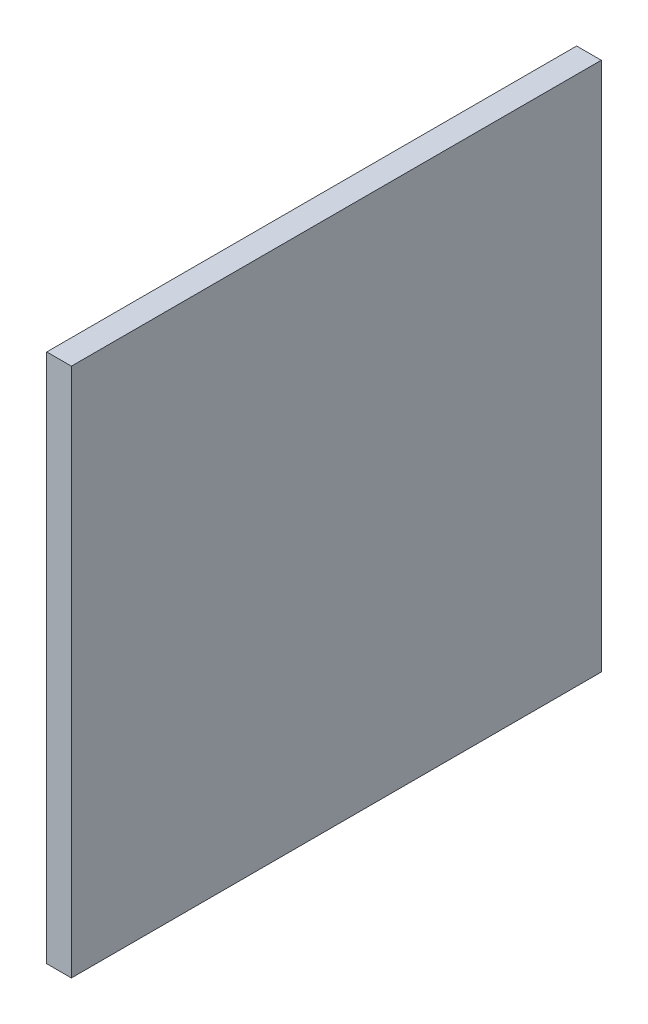
from build123d import *

# Parameters (mm, degrees)
SKETCH2_W              = 43
SKETCH2_H              = 43
BOSS_EXTRUDE1_DEPTH    = 2
SKETCH3_R              = 1.5
BOSS_EXTRUDE5_DEPTH    = 4
SKETCH5_R              = 1.5
BOSS_EXTRUDE6_DEPTH    = 4
BOSS_EXTRUDE6_2_DEPTH  = 4
BOSS_EXTRUDE6_3_DEPTH  = 4
BOSS_EXTRUDE6_4_DEPTH  = 4
BOSS_EXTRUDE6_5_DEPTH  = 4
BOSS_EXTRUDE6_6_DEPTH  = 4
BOSS_EXTRUDE6_7_DEPTH  = 4
BOSS_EXTRUDE6_8_DEPTH  = 4
SKETCH5_R_2            = 1.51
BOSS_EXTRUDE6_9_DEPTH  = 4
BOSS_EXTRUDE6_10_DEPTH = 4
BOSS_EXTRUDE6_11_DEPTH = 4
BOSS_EXTRUDE6_12_DEPTH = 4
BOSS_EXTRUDE6_13_DEPTH = 4
BOSS_EXTRUDE6_14_DEPTH = 4
BOSS_EXTRUDE6_15_DEPTH = 4
BOSS_EXTRUDE6_16_DEPTH = 4
BOSS_EXTRUDE6_17_DEPTH = 4
BOSS_EXTRUDE6_18_DEPTH = 4
BOSS_EXTRUDE6_19_DEPTH = 4
BOSS_EXTRUDE6_20_DEPTH = 4
BOSS_EXTRUDE6_21_DEPTH = 4
BOSS_EXTRUDE6_22_DEPTH = 4
BOSS_EXTRUDE6_23_DEPTH = 4
BOSS_EXTRUDE6_24_DEPTH = 4
BOSS_EXTRUDE6_25_DEPTH = 4
BOSS_EXTRUDE6_26_DEPTH = 4
BOSS_EXTRUDE6_27_DEPTH = 4
BOSS_EXTRUDE6_28_DEPTH = 4
BOSS_EXTRUDE6_29_DEPTH = 4
BOSS_EXTRUDE6_30_DEPTH = 4
BOSS_EXTRUDE6_31_DEPTH = 4
BOSS_EXTRUDE6_32_DEPTH = 4
BOSS_EXTRUDE6_33_DEPTH = 4
BOSS_EXTRUDE6_34_DEPTH = 4
BOSS_EXTRUDE6_35_DEPTH = 4
BOSS_EXTRUDE6_36_DEPTH = 4
BOSS_EXTRUDE6_37_DEPTH = 4
BOSS_EXTRUDE6_38_DEPTH = 4
BOSS_EXTRUDE6_39_DEPTH = 4
BOSS_EXTRUDE6_40_DEPTH = 4
BOSS_EXTRUDE6_41_DEPTH = 4
BOSS_EXTRUDE6_42_DEPTH = 4
BOSS_EXTRUDE6_43_DEPTH = 4
BOSS_EXTRUDE6_44_DEPTH = 4
BOSS_EXTRUDE6_45_DEPTH = 4
BOSS_EXTRUDE6_46_DEPTH = 4
BOSS_EXTRUDE6_47_DEPTH = 4
BOSS_EXTRUDE6_48_DEPTH = 4
BOSS_EXTRUDE6_49_DEPTH = 4
BOSS_EXTRUDE6_50_DEPTH = 4
BOSS_EXTRUDE6_51_DEPTH = 4
BOSS_EXTRUDE6_52_DEPTH = 4
BOSS_EXTRUDE6_53_DEPTH = 4
BOSS_EXTRUDE6_54_DEPTH = 4
BOSS_EXTRUDE6_55_DEPTH = 4
BOSS_EXTRUDE6_56_DEPTH = 4
FILLET3_R              = 1
FILLET4_R              = 1
FILLET5_R              = 1
FILLET6_R              = 1
FILLET7_R              = 1
FILLET8_R              = 1
FILLET9_R              = 1
FILLET10_R             = 1
FILLET11_R             = 1
FILLET12_R             = 1
FILLET13_R             = 1
FILLET14_R             = 1
FILLET15_R             = 1
FILLET16_R             = 1
FILLET17_R             = 1
FILLET18_R             = 1
FILLET19_R             = 1
FILLET20_R             = 1
FILLET21_R             = 1
FILLET22_R             = 1
FILLET23_R             = 1
FILLET24_R             = 1
FILLET25_R             = 1
FILLET26_R             = 1
FILLET27_R             = 1
FILLET28_R             = 1
FILLET29_R             = 1
FILLET30_R             = 1
FILLET31_R             = 1
FILLET32_R             = 1
FILLET33_R             = 1
FILLET34_R             = 1
FILLET35_R             = 1
FILLET36_R             = 1
FILLET37_R             = 1
FILLET38_R             = 1
FILLET39_R             = 1
FILLET40_R             = 1
FILLET41_R             = 1
FILLET42_R             = 1
FILLET43_R             = 1
FILLET44_R             = 1
FILLET45_R             = 1
FILLET46_R             = 1
FILLET47_R             = 1
FILLET48_R             = 1
FILLET49_R             = 1
FILLET50_R             = 1
FILLET51_R             = 1
FILLET52_R             = 1
FILLET53_R             = 1
FILLET54_R             = 1
FILLET55_R             = 1
FILLET56_R             = 1
FILLET57_R             = 1
FILLET58_R             = 1
FILLET59_R             = 1
FILLET60_R             = 1


with BuildPart() as part:
    # Sketch2 → Boss-Extrude1 (new body)
    with BuildSketch(Plane(origin=(0, 0, 0), x_dir=(0, 0, -1), z_dir=(1, 0, 0))):
        with Locations((21.5, 21.5)):
            Rectangle(SKETCH2_W, SKETCH2_H)
    extrude(amount=BOSS_EXTRUDE1_DEPTH)

    # Sketch3 → Boss-Extrude5 (add)
    with BuildSketch(Plane(origin=(0, 0, 0), x_dir=(0, 0, -1), z_dir=(1, 0, 0))):
        with Locations((6.1, 36.65749204)):
            Circle(SKETCH3_R)
        with Locations((10.4, 36.65749204)):
            Circle(SKETCH3_R)
        with Locations((14.7, 36.65749204)):
            Circle(SKETCH3_R)
        with Locations((19, 36.65749204)):
            Circle(SKETCH3_R)
        with Locations((23.3, 36.65749204)):
            Circle(SKETCH3_R)
        with Locations((27.6, 36.65749204)):
            Circle(SKETCH3_R)
        with Locations((31.93, 36.65749204)):
            Circle(SKETCH3_R)
        with Locations((36.23, 36.65749204)):
            Circle(SKETCH3_R)
    extrude(amount=-BOSS_EXTRUDE5_DEPTH)

    # Fillet3
    fillet3_edges = [part.edges().sort_by_distance(p)[0] for p in [
        (-4, 36.65749204, -34.73),
    ]]
    fillet(fillet3_edges, radius=FILLET3_R)

    # Fillet4
    fillet4_edges = [part.edges().sort_by_distance(p)[0] for p in [
        (-4, 36.65749204, -4.6),
        (-4, 36.65749204, -13.2),
        (-4, 36.65749204, -8.9),
        (-4, 36.65749204, -17.5),
        (-4, 36.65749204, -26.1),
        (-4, 36.65749204, -30.43),
        (-4, 36.65749204, -21.8),
    ]]
    fillet(fillet4_edges, radius=FILLET4_R)


with BuildPart() as body_2:
    # Sketch5 → Boss-Extrude6 (new body)
    with BuildSketch(Plane(origin=(0, 0, 0), x_dir=(0, 0, -1), z_dir=(1, 0, 0))):
        with Locations((36.23, 32.354858463)):
            Circle(SKETCH5_R)
    extrude(amount=-BOSS_EXTRUDE6_DEPTH)

    # Fillet5
    fillet5_edges = [body_2.edges().sort_by_distance(p)[0] for p in [
        (-4, 32.354858463, -34.73),
    ]]
    fillet(fillet5_edges, radius=FILLET5_R)


with BuildPart() as body_3:
    # Sketch5 → Boss-Extrude6 2 (new body)
    with BuildSketch(Plane(origin=(0, 0, 0), x_dir=(0, 0, -1), z_dir=(1, 0, 0))):
        with Locations((31.933627596, 32.354858463)):
            Circle(SKETCH5_R)
    extrude(amount=-BOSS_EXTRUDE6_2_DEPTH)

    # Fillet6
    fillet6_edges = [body_3.edges().sort_by_distance(p)[0] for p in [
        (-4, 32.354858463, -30.433627596),
    ]]
    fillet(fillet6_edges, radius=FILLET6_R)


with BuildPart() as body_4:
    # Sketch5 → Boss-Extrude6 3 (new body)
    with BuildSketch(Plane(origin=(0, 0, 0), x_dir=(0, 0, -1), z_dir=(1, 0, 0))):
        with Locations((27.633627596, 32.354858463)):
            Circle(SKETCH5_R)
    extrude(amount=-BOSS_EXTRUDE6_3_DEPTH)

    # Fillet7
    fillet7_edges = [body_4.edges().sort_by_distance(p)[0] for p in [
        (-4, 32.354858463, -26.133627596),
    ]]
    fillet(fillet7_edges, radius=FILLET7_R)


with BuildPart() as body_5:
    # Sketch5 → Boss-Extrude6 4 (new body)
    with BuildSketch(Plane(origin=(0, 0, 0), x_dir=(0, 0, -1), z_dir=(1, 0, 0))):
        with Locations((23.333627596, 32.354858463)):
            Circle(SKETCH5_R)
    extrude(amount=-BOSS_EXTRUDE6_4_DEPTH)

    # Fillet8
    fillet8_edges = [body_5.edges().sort_by_distance(p)[0] for p in [
        (-4, 32.354858463, -21.833627596),
    ]]
    fillet(fillet8_edges, radius=FILLET8_R)


with BuildPart() as body_6:
    # Sketch5 → Boss-Extrude6 5 (new body)
    with BuildSketch(Plane(origin=(0, 0, 0), x_dir=(0, 0, -1), z_dir=(1, 0, 0))):
        with Locations((19.033627596, 32.354858463)):
            Circle(SKETCH5_R)
    extrude(amount=-BOSS_EXTRUDE6_5_DEPTH)

    # Fillet9
    fillet9_edges = [body_6.edges().sort_by_distance(p)[0] for p in [
        (-4, 32.354858463, -17.533627596),
    ]]
    fillet(fillet9_edges, radius=FILLET9_R)


with BuildPart() as body_7:
    # Sketch5 → Boss-Extrude6 6 (new body)
    with BuildSketch(Plane(origin=(0, 0, 0), x_dir=(0, 0, -1), z_dir=(1, 0, 0))):
        with Locations((14.733627596, 32.354858463)):
            Circle(SKETCH5_R)
    extrude(amount=-BOSS_EXTRUDE6_6_DEPTH)

    # Fillet10
    fillet10_edges = [body_7.edges().sort_by_distance(p)[0] for p in [
        (-4, 32.354858463, -13.233627596),
    ]]
    fillet(fillet10_edges, radius=FILLET10_R)


with BuildPart() as body_8:
    # Sketch5 → Boss-Extrude6 7 (new body)
    with BuildSketch(Plane(origin=(0, 0, 0), x_dir=(0, 0, -1), z_dir=(1, 0, 0))):
        with Locations((10.433627596, 32.354858463)):
            Circle(SKETCH5_R)
    extrude(amount=-BOSS_EXTRUDE6_7_DEPTH)

    # Fillet11
    fillet11_edges = [body_8.edges().sort_by_distance(p)[0] for p in [
        (-4, 32.354858463, -8.933627596),
    ]]
    fillet(fillet11_edges, radius=FILLET11_R)


with BuildPart() as body_9:
    # Sketch5 → Boss-Extrude6 8 (new body)
    with BuildSketch(Plane(origin=(0, 0, 0), x_dir=(0, 0, -1), z_dir=(1, 0, 0))):
        with Locations((6.133627596, 32.354858463)):
            Circle(SKETCH5_R)
    extrude(amount=-BOSS_EXTRUDE6_8_DEPTH)

    # Fillet12
    fillet12_edges = [body_9.edges().sort_by_distance(p)[0] for p in [
        (-4, 32.354858463, -4.633627596),
    ]]
    fillet(fillet12_edges, radius=FILLET12_R)


with BuildPart() as body_10:
    # Sketch5 → Boss-Extrude6 9 (new body)
    with BuildSketch(Plane(origin=(0, 0, 0), x_dir=(0, 0, -1), z_dir=(1, 0, 0))):
        with Locations((6.133627596, 28.054858463)):
            Circle(SKETCH5_R_2)
    extrude(amount=-BOSS_EXTRUDE6_9_DEPTH)

    # Fillet19
    fillet19_edges = [body_10.edges().sort_by_distance(p)[0] for p in [
        (-4, 28.054858463, -4.623627596),
    ]]
    fillet(fillet19_edges, radius=FILLET19_R)


with BuildPart() as body_11:
    # Sketch5 → Boss-Extrude6 10 (new body)
    with BuildSketch(Plane(origin=(0, 0, 0), x_dir=(0, 0, -1), z_dir=(1, 0, 0))):
        with Locations((10.433627596, 28.054858463)):
            Circle(SKETCH5_R)
    extrude(amount=-BOSS_EXTRUDE6_10_DEPTH)

    # Fillet20
    fillet20_edges = [body_11.edges().sort_by_distance(p)[0] for p in [
        (-4, 28.054858463, -8.933627596),
    ]]
    fillet(fillet20_edges, radius=FILLET20_R)


with BuildPart() as body_12:
    # Sketch5 → Boss-Extrude6 11 (new body)
    with BuildSketch(Plane(origin=(0, 0, 0), x_dir=(0, 0, -1), z_dir=(1, 0, 0))):
        with Locations((14.733627596, 28.054858463)):
            Circle(SKETCH5_R)
    extrude(amount=-BOSS_EXTRUDE6_11_DEPTH)

    # Fillet18
    fillet18_edges = [body_12.edges().sort_by_distance(p)[0] for p in [
        (-4, 28.054858463, -13.233627596),
    ]]
    fillet(fillet18_edges, radius=FILLET18_R)


with BuildPart() as body_13:
    # Sketch5 → Boss-Extrude6 12 (new body)
    with BuildSketch(Plane(origin=(0, 0, 0), x_dir=(0, 0, -1), z_dir=(1, 0, 0))):
        with Locations((19.033627596, 28.054858463)):
            Circle(SKETCH5_R)
    extrude(amount=-BOSS_EXTRUDE6_12_DEPTH)

    # Fillet17
    fillet17_edges = [body_13.edges().sort_by_distance(p)[0] for p in [
        (-4, 28.054858463, -17.533627596),
    ]]
    fillet(fillet17_edges, radius=FILLET17_R)


with BuildPart() as body_14:
    # Sketch5 → Boss-Extrude6 13 (new body)
    with BuildSketch(Plane(origin=(0, 0, 0), x_dir=(0, 0, -1), z_dir=(1, 0, 0))):
        with Locations((23.333627596, 28.054858463)):
            Circle(SKETCH5_R)
    extrude(amount=-BOSS_EXTRUDE6_13_DEPTH)

    # Fillet16
    fillet16_edges = [body_14.edges().sort_by_distance(p)[0] for p in [
        (-4, 28.054858463, -21.833627596),
    ]]
    fillet(fillet16_edges, radius=FILLET16_R)


with BuildPart() as body_15:
    # Sketch5 → Boss-Extrude6 14 (new body)
    with BuildSketch(Plane(origin=(0, 0, 0), x_dir=(0, 0, -1), z_dir=(1, 0, 0))):
        with Locations((27.633627596, 28.054858463)):
            Circle(SKETCH5_R)
    extrude(amount=-BOSS_EXTRUDE6_14_DEPTH)

    # Fillet15
    fillet15_edges = [body_15.edges().sort_by_distance(p)[0] for p in [
        (-4, 28.054858463, -26.133627596),
    ]]
    fillet(fillet15_edges, radius=FILLET15_R)


with BuildPart() as body_16:
    # Sketch5 → Boss-Extrude6 15 (new body)
    with BuildSketch(Plane(origin=(0, 0, 0), x_dir=(0, 0, -1), z_dir=(1, 0, 0))):
        with Locations((31.933627596, 28.054858463)):
            Circle(SKETCH5_R)
    extrude(amount=-BOSS_EXTRUDE6_15_DEPTH)

    # Fillet14
    fillet14_edges = [body_16.edges().sort_by_distance(p)[0] for p in [
        (-4, 28.054858463, -30.433627596),
    ]]
    fillet(fillet14_edges, radius=FILLET14_R)


with BuildPart() as body_17:
    # Sketch5 → Boss-Extrude6 16 (new body)
    with BuildSketch(Plane(origin=(0, 0, 0), x_dir=(0, 0, -1), z_dir=(1, 0, 0))):
        with Locations((36.23, 28.054858463)):
            Circle(SKETCH5_R)
    extrude(amount=-BOSS_EXTRUDE6_16_DEPTH)

    # Fillet13
    fillet13_edges = [body_17.edges().sort_by_distance(p)[0] for p in [
        (-4, 28.054858463, -34.73),
    ]]
    fillet(fillet13_edges, radius=FILLET13_R)


with BuildPart() as body_18:
    # Sketch5 → Boss-Extrude6 17 (new body)
    with BuildSketch(Plane(origin=(0, 0, 0), x_dir=(0, 0, -1), z_dir=(1, 0, 0))):
        with Locations((36.23, 23.754858463)):
            Circle(SKETCH5_R)
    extrude(amount=-BOSS_EXTRUDE6_17_DEPTH)

    # Fillet28
    fillet28_edges = [body_18.edges().sort_by_distance(p)[0] for p in [
        (-4, 23.754858463, -34.73),
    ]]
    fillet(fillet28_edges, radius=FILLET28_R)


with BuildPart() as body_19:
    # Sketch5 → Boss-Extrude6 18 (new body)
    with BuildSketch(Plane(origin=(0, 0, 0), x_dir=(0, 0, -1), z_dir=(1, 0, 0))):
        with Locations((31.933627596, 23.754858463)):
            Circle(SKETCH5_R)
    extrude(amount=-BOSS_EXTRUDE6_18_DEPTH)

    # Fillet27
    fillet27_edges = [body_19.edges().sort_by_distance(p)[0] for p in [
        (-4, 23.754858463, -30.433627596),
    ]]
    fillet(fillet27_edges, radius=FILLET27_R)


with BuildPart() as body_20:
    # Sketch5 → Boss-Extrude6 19 (new body)
    with BuildSketch(Plane(origin=(0, 0, 0), x_dir=(0, 0, -1), z_dir=(1, 0, 0))):
        with Locations((27.633627596, 23.754858463)):
            Circle(SKETCH5_R)
    extrude(amount=-BOSS_EXTRUDE6_19_DEPTH)

    # Fillet26
    fillet26_edges = [body_20.edges().sort_by_distance(p)[0] for p in [
        (-4, 23.754858463, -26.133627596),
    ]]
    fillet(fillet26_edges, radius=FILLET26_R)


with BuildPart() as body_21:
    # Sketch5 → Boss-Extrude6 20 (new body)
    with BuildSketch(Plane(origin=(0, 0, 0), x_dir=(0, 0, -1), z_dir=(1, 0, 0))):
        with Locations((23.333627596, 23.754858463)):
            Circle(SKETCH5_R)
    extrude(amount=-BOSS_EXTRUDE6_20_DEPTH)

    # Fillet25
    fillet25_edges = [body_21.edges().sort_by_distance(p)[0] for p in [
        (-4, 23.754858463, -21.833627596),
    ]]
    fillet(fillet25_edges, radius=FILLET25_R)


with BuildPart() as body_22:
    # Sketch5 → Boss-Extrude6 21 (new body)
    with BuildSketch(Plane(origin=(0, 0, 0), x_dir=(0, 0, -1), z_dir=(1, 0, 0))):
        with Locations((19.033627596, 23.754858463)):
            Circle(SKETCH5_R)
    extrude(amount=-BOSS_EXTRUDE6_21_DEPTH)

    # Fillet24
    fillet24_edges = [body_22.edges().sort_by_distance(p)[0] for p in [
        (-4, 23.754858463, -17.533627596),
    ]]
    fillet(fillet24_edges, radius=FILLET24_R)


with BuildPart() as body_23:
    # Sketch5 → Boss-Extrude6 22 (new body)
    with BuildSketch(Plane(origin=(0, 0, 0), x_dir=(0, 0, -1), z_dir=(1, 0, 0))):
        with Locations((14.733627596, 23.754858463)):
            Circle(SKETCH5_R)
    extrude(amount=-BOSS_EXTRUDE6_22_DEPTH)

    # Fillet23
    fillet23_edges = [body_23.edges().sort_by_distance(p)[0] for p in [
        (-4, 23.754858463, -13.233627596),
    ]]
    fillet(fillet23_edges, radius=FILLET23_R)


with BuildPart() as body_24:
    # Sketch5 → Boss-Extrude6 23 (new body)
    with BuildSketch(Plane(origin=(0, 0, 0), x_dir=(0, 0, -1), z_dir=(1, 0, 0))):
        with Locations((10.433627596, 23.754858463)):
            Circle(SKETCH5_R)
    extrude(amount=-BOSS_EXTRUDE6_23_DEPTH)

    # Fillet21
    fillet21_edges = [body_24.edges().sort_by_distance(p)[0] for p in [
        (-4, 23.754858463, -8.933627596),
    ]]
    fillet(fillet21_edges, radius=FILLET21_R)


with BuildPart() as body_25:
    # Sketch5 → Boss-Extrude6 24 (new body)
    with BuildSketch(Plane(origin=(0, 0, 0), x_dir=(0, 0, -1), z_dir=(1, 0, 0))):
        with Locations((6.133627596, 23.754858463)):
            Circle(SKETCH5_R)
    extrude(amount=-BOSS_EXTRUDE6_24_DEPTH)

    # Fillet22
    fillet22_edges = [body_25.edges().sort_by_distance(p)[0] for p in [
        (-4, 23.754858463, -4.633627596),
    ]]
    fillet(fillet22_edges, radius=FILLET22_R)


with BuildPart() as body_26:
    # Sketch5 → Boss-Extrude6 25 (new body)
    with BuildSketch(Plane(origin=(0, 0, 0), x_dir=(0, 0, -1), z_dir=(1, 0, 0))):
        with Locations((6.133627596, 19.454858463)):
            Circle(SKETCH5_R)
    extrude(amount=-BOSS_EXTRUDE6_25_DEPTH)

    # Fillet36
    fillet36_edges = [body_26.edges().sort_by_distance(p)[0] for p in [
        (0, 19.454858463, -4.633627596),
        (-4, 19.454858463, -4.633627596),
    ]]
    fillet(fillet36_edges, radius=FILLET36_R)


with BuildPart() as body_27:
    # Sketch5 → Boss-Extrude6 26 (new body)
    with BuildSketch(Plane(origin=(0, 0, 0), x_dir=(0, 0, -1), z_dir=(1, 0, 0))):
        with Locations((10.433627596, 19.454858463)):
            Circle(SKETCH5_R)
    extrude(amount=-BOSS_EXTRUDE6_26_DEPTH)

    # Fillet35
    fillet35_edges = [body_27.edges().sort_by_distance(p)[0] for p in [
        (-4, 19.454858463, -8.933627596),
    ]]
    fillet(fillet35_edges, radius=FILLET35_R)


with BuildPart() as body_28:
    # Sketch5 → Boss-Extrude6 27 (new body)
    with BuildSketch(Plane(origin=(0, 0, 0), x_dir=(0, 0, -1), z_dir=(1, 0, 0))):
        with Locations((14.733627596, 19.454858463)):
            Circle(SKETCH5_R)
    extrude(amount=-BOSS_EXTRUDE6_27_DEPTH)

    # Fillet34
    fillet34_edges = [body_28.edges().sort_by_distance(p)[0] for p in [
        (-4, 19.454858463, -13.233627596),
    ]]
    fillet(fillet34_edges, radius=FILLET34_R)


with BuildPart() as body_29:
    # Sketch5 → Boss-Extrude6 28 (new body)
    with BuildSketch(Plane(origin=(0, 0, 0), x_dir=(0, 0, -1), z_dir=(1, 0, 0))):
        with Locations((19.033627596, 19.454858463)):
            Circle(SKETCH5_R)
    extrude(amount=-BOSS_EXTRUDE6_28_DEPTH)

    # Fillet33
    fillet33_edges = [body_29.edges().sort_by_distance(p)[0] for p in [
        (-4, 19.454858463, -17.533627596),
    ]]
    fillet(fillet33_edges, radius=FILLET33_R)


with BuildPart() as body_30:
    # Sketch5 → Boss-Extrude6 29 (new body)
    with BuildSketch(Plane(origin=(0, 0, 0), x_dir=(0, 0, -1), z_dir=(1, 0, 0))):
        with Locations((23.333627596, 19.454858463)):
            Circle(SKETCH5_R)
    extrude(amount=-BOSS_EXTRUDE6_29_DEPTH)

    # Fillet32
    fillet32_edges = [body_30.edges().sort_by_distance(p)[0] for p in [
        (-4, 19.454858463, -21.833627596),
    ]]
    fillet(fillet32_edges, radius=FILLET32_R)


with BuildPart() as body_31:
    # Sketch5 → Boss-Extrude6 30 (new body)
    with BuildSketch(Plane(origin=(0, 0, 0), x_dir=(0, 0, -1), z_dir=(1, 0, 0))):
        with Locations((27.633627596, 19.454858463)):
            Circle(SKETCH5_R)
    extrude(amount=-BOSS_EXTRUDE6_30_DEPTH)

    # Fillet31
    fillet31_edges = [body_31.edges().sort_by_distance(p)[0] for p in [
        (-4, 19.454858463, -26.133627596),
    ]]
    fillet(fillet31_edges, radius=FILLET31_R)


with BuildPart() as body_32:
    # Sketch5 → Boss-Extrude6 31 (new body)
    with BuildSketch(Plane(origin=(0, 0, 0), x_dir=(0, 0, -1), z_dir=(1, 0, 0))):
        with Locations((31.933627596, 19.454858463)):
            Circle(SKETCH5_R)
    extrude(amount=-BOSS_EXTRUDE6_31_DEPTH)

    # Fillet30
    fillet30_edges = [body_32.edges().sort_by_distance(p)[0] for p in [
        (-4, 19.454858463, -30.433627596),
    ]]
    fillet(fillet30_edges, radius=FILLET30_R)


with BuildPart() as body_33:
    # Sketch5 → Boss-Extrude6 32 (new body)
    with BuildSketch(Plane(origin=(0, 0, 0), x_dir=(0, 0, -1), z_dir=(1, 0, 0))):
        with Locations((36.23, 19.454858463)):
            Circle(SKETCH5_R)
    extrude(amount=-BOSS_EXTRUDE6_32_DEPTH)

    # Fillet29
    fillet29_edges = [body_33.edges().sort_by_distance(p)[0] for p in [
        (-4, 19.454858463, -34.73),
    ]]
    fillet(fillet29_edges, radius=FILLET29_R)


with BuildPart() as body_34:
    # Sketch5 → Boss-Extrude6 33 (new body)
    with BuildSketch(Plane(origin=(0, 0, 0), x_dir=(0, 0, -1), z_dir=(1, 0, 0))):
        with Locations((36.23, 15.154858463)):
            Circle(SKETCH5_R)
    extrude(amount=-BOSS_EXTRUDE6_33_DEPTH)

    # Fillet44
    fillet44_edges = [body_34.edges().sort_by_distance(p)[0] for p in [
        (-4, 15.154858463, -34.73),
    ]]
    fillet(fillet44_edges, radius=FILLET44_R)


with BuildPart() as body_35:
    # Sketch5 → Boss-Extrude6 34 (new body)
    with BuildSketch(Plane(origin=(0, 0, 0), x_dir=(0, 0, -1), z_dir=(1, 0, 0))):
        with Locations((31.933627596, 15.154858463)):
            Circle(SKETCH5_R)
    extrude(amount=-BOSS_EXTRUDE6_34_DEPTH)

    # Fillet43
    fillet43_edges = [body_35.edges().sort_by_distance(p)[0] for p in [
        (-4, 15.154858463, -30.433627596),
    ]]
    fillet(fillet43_edges, radius=FILLET43_R)


with BuildPart() as body_36:
    # Sketch5 → Boss-Extrude6 35 (new body)
    with BuildSketch(Plane(origin=(0, 0, 0), x_dir=(0, 0, -1), z_dir=(1, 0, 0))):
        with Locations((27.633627596, 15.154858463)):
            Circle(SKETCH5_R)
    extrude(amount=-BOSS_EXTRUDE6_35_DEPTH)

    # Fillet42
    fillet42_edges = [body_36.edges().sort_by_distance(p)[0] for p in [
        (-4, 15.154858463, -26.133627596),
    ]]
    fillet(fillet42_edges, radius=FILLET42_R)


with BuildPart() as body_37:
    # Sketch5 → Boss-Extrude6 36 (new body)
    with BuildSketch(Plane(origin=(0, 0, 0), x_dir=(0, 0, -1), z_dir=(1, 0, 0))):
        with Locations((23.333627596, 15.154858463)):
            Circle(SKETCH5_R)
    extrude(amount=-BOSS_EXTRUDE6_36_DEPTH)

    # Fillet41
    fillet41_edges = [body_37.edges().sort_by_distance(p)[0] for p in [
        (-4, 15.154858463, -21.833627596),
    ]]
    fillet(fillet41_edges, radius=FILLET41_R)


with BuildPart() as body_38:
    # Sketch5 → Boss-Extrude6 37 (new body)
    with BuildSketch(Plane(origin=(0, 0, 0), x_dir=(0, 0, -1), z_dir=(1, 0, 0))):
        with Locations((19.033627596, 15.154858463)):
            Circle(SKETCH5_R)
    extrude(amount=-BOSS_EXTRUDE6_37_DEPTH)

    # Fillet40
    fillet40_edges = [body_38.edges().sort_by_distance(p)[0] for p in [
        (-4, 15.154858463, -17.533627596),
    ]]
    fillet(fillet40_edges, radius=FILLET40_R)


with BuildPart() as body_39:
    # Sketch5 → Boss-Extrude6 38 (new body)
    with BuildSketch(Plane(origin=(0, 0, 0), x_dir=(0, 0, -1), z_dir=(1, 0, 0))):
        with Locations((14.733627596, 15.154858463)):
            Circle(SKETCH5_R)
    extrude(amount=-BOSS_EXTRUDE6_38_DEPTH)

    # Fillet39
    fillet39_edges = [body_39.edges().sort_by_distance(p)[0] for p in [
        (-4, 15.154858463, -13.233627596),
    ]]
    fillet(fillet39_edges, radius=FILLET39_R)


with BuildPart() as body_40:
    # Sketch5 → Boss-Extrude6 39 (new body)
    with BuildSketch(Plane(origin=(0, 0, 0), x_dir=(0, 0, -1), z_dir=(1, 0, 0))):
        with Locations((10.433627596, 15.154858463)):
            Circle(SKETCH5_R)
    extrude(amount=-BOSS_EXTRUDE6_39_DEPTH)

    # Fillet38
    fillet38_edges = [body_40.edges().sort_by_distance(p)[0] for p in [
        (-4, 15.154858463, -8.933627596),
    ]]
    fillet(fillet38_edges, radius=FILLET38_R)


with BuildPart() as body_41:
    # Sketch5 → Boss-Extrude6 40 (new body)
    with BuildSketch(Plane(origin=(0, 0, 0), x_dir=(0, 0, -1), z_dir=(1, 0, 0))):
        with Locations((6.133627596, 15.154858463)):
            Circle(SKETCH5_R)
    extrude(amount=-BOSS_EXTRUDE6_40_DEPTH)

    # Fillet37
    fillet37_edges = [body_41.edges().sort_by_distance(p)[0] for p in [
        (-4, 15.154858463, -4.633627596),
    ]]
    fillet(fillet37_edges, radius=FILLET37_R)


with BuildPart() as body_42:
    # Sketch5 → Boss-Extrude6 41 (new body)
    with BuildSketch(Plane(origin=(0, 0, 0), x_dir=(0, 0, -1), z_dir=(1, 0, 0))):
        with Locations((6.133627596, 10.854858463)):
            Circle(SKETCH5_R)
    extrude(amount=-BOSS_EXTRUDE6_41_DEPTH)

    # Fillet52
    fillet52_edges = [body_42.edges().sort_by_distance(p)[0] for p in [
        (-4, 10.854858463, -4.633627596),
    ]]
    fillet(fillet52_edges, radius=FILLET52_R)


with BuildPart() as body_43:
    # Sketch5 → Boss-Extrude6 42 (new body)
    with BuildSketch(Plane(origin=(0, 0, 0), x_dir=(0, 0, -1), z_dir=(1, 0, 0))):
        with Locations((10.433627596, 10.854858463)):
            Circle(SKETCH5_R)
    extrude(amount=-BOSS_EXTRUDE6_42_DEPTH)

    # Fillet51
    fillet51_edges = [body_43.edges().sort_by_distance(p)[0] for p in [
        (-4, 10.854858463, -8.933627596),
    ]]
    fillet(fillet51_edges, radius=FILLET51_R)


with BuildPart() as body_44:
    # Sketch5 → Boss-Extrude6 43 (new body)
    with BuildSketch(Plane(origin=(0, 0, 0), x_dir=(0, 0, -1), z_dir=(1, 0, 0))):
        with Locations((14.733627596, 10.854858463)):
            Circle(SKETCH5_R)
    extrude(amount=-BOSS_EXTRUDE6_43_DEPTH)

    # Fillet50
    fillet50_edges = [body_44.edges().sort_by_distance(p)[0] for p in [
        (-4, 10.854858463, -13.233627596),
    ]]
    fillet(fillet50_edges, radius=FILLET50_R)


with BuildPart() as body_45:
    # Sketch5 → Boss-Extrude6 44 (new body)
    with BuildSketch(Plane(origin=(0, 0, 0), x_dir=(0, 0, -1), z_dir=(1, 0, 0))):
        with Locations((19.033627596, 10.854858463)):
            Circle(SKETCH5_R)
    extrude(amount=-BOSS_EXTRUDE6_44_DEPTH)

    # Fillet49
    fillet49_edges = [body_45.edges().sort_by_distance(p)[0] for p in [
        (-4, 10.854858463, -17.533627596),
    ]]
    fillet(fillet49_edges, radius=FILLET49_R)


with BuildPart() as body_46:
    # Sketch5 → Boss-Extrude6 45 (new body)
    with BuildSketch(Plane(origin=(0, 0, 0), x_dir=(0, 0, -1), z_dir=(1, 0, 0))):
        with Locations((23.333627596, 10.854858463)):
            Circle(SKETCH5_R)
    extrude(amount=-BOSS_EXTRUDE6_45_DEPTH)

    # Fillet48
    fillet48_edges = [body_46.edges().sort_by_distance(p)[0] for p in [
        (-4, 10.854858463, -21.833627596),
    ]]
    fillet(fillet48_edges, radius=FILLET48_R)


with BuildPart() as body_47:
    # Sketch5 → Boss-Extrude6 46 (new body)
    with BuildSketch(Plane(origin=(0, 0, 0), x_dir=(0, 0, -1), z_dir=(1, 0, 0))):
        with Locations((27.633627596, 10.854858463)):
            Circle(SKETCH5_R)
    extrude(amount=-BOSS_EXTRUDE6_46_DEPTH)

    # Fillet47
    fillet47_edges = [body_47.edges().sort_by_distance(p)[0] for p in [
        (-4, 10.854858463, -26.133627596),
    ]]
    fillet(fillet47_edges, radius=FILLET47_R)


with BuildPart() as body_48:
    # Sketch5 → Boss-Extrude6 47 (new body)
    with BuildSketch(Plane(origin=(0, 0, 0), x_dir=(0, 0, -1), z_dir=(1, 0, 0))):
        with Locations((31.933627596, 10.854858463)):
            Circle(SKETCH5_R)
    extrude(amount=-BOSS_EXTRUDE6_47_DEPTH)

    # Fillet46
    fillet46_edges = [body_48.edges().sort_by_distance(p)[0] for p in [
        (-4, 10.854858463, -30.433627596),
    ]]
    fillet(fillet46_edges, radius=FILLET46_R)


with BuildPart() as body_49:
    # Sketch5 → Boss-Extrude6 48 (new body)
    with BuildSketch(Plane(origin=(0, 0, 0), x_dir=(0, 0, -1), z_dir=(1, 0, 0))):
        with Locations((36.23, 10.854858463)):
            Circle(SKETCH5_R)
    extrude(amount=-BOSS_EXTRUDE6_48_DEPTH)

    # Fillet45
    fillet45_edges = [body_49.edges().sort_by_distance(p)[0] for p in [
        (-4, 10.854858463, -34.73),
    ]]
    fillet(fillet45_edges, radius=FILLET45_R)


with BuildPart() as body_50:
    # Sketch5 → Boss-Extrude6 49 (new body)
    with BuildSketch(Plane(origin=(0, 0, 0), x_dir=(0, 0, -1), z_dir=(1, 0, 0))):
        with Locations((36.23, 6.554858463)):
            Circle(SKETCH5_R)
    extrude(amount=-BOSS_EXTRUDE6_49_DEPTH)

    # Fillet59
    fillet59_edges = [body_50.edges().sort_by_distance(p)[0] for p in [
        (-4, 6.554858463, -34.73),
    ]]
    fillet(fillet59_edges, radius=FILLET59_R)


with BuildPart() as body_51:
    # Sketch5 → Boss-Extrude6 50 (new body)
    with BuildSketch(Plane(origin=(0, 0, 0), x_dir=(0, 0, -1), z_dir=(1, 0, 0))):
        with Locations((31.933627596, 6.554858463)):
            Circle(SKETCH5_R)
    extrude(amount=-BOSS_EXTRUDE6_50_DEPTH)

    # Fillet58
    fillet58_edges = [body_51.edges().sort_by_distance(p)[0] for p in [
        (-4, 6.554858463, -30.433627596),
    ]]
    fillet(fillet58_edges, radius=FILLET58_R)


with BuildPart() as body_52:
    # Sketch5 → Boss-Extrude6 51 (new body)
    with BuildSketch(Plane(origin=(0, 0, 0), x_dir=(0, 0, -1), z_dir=(1, 0, 0))):
        with Locations((27.633627596, 6.554858463)):
            Circle(SKETCH5_R)
    extrude(amount=-BOSS_EXTRUDE6_51_DEPTH)

    # Fillet57
    fillet57_edges = [body_52.edges().sort_by_distance(p)[0] for p in [
        (-4, 6.554858463, -26.133627596),
    ]]
    fillet(fillet57_edges, radius=FILLET57_R)


with BuildPart() as body_53:
    # Sketch5 → Boss-Extrude6 52 (new body)
    with BuildSketch(Plane(origin=(0, 0, 0), x_dir=(0, 0, -1), z_dir=(1, 0, 0))):
        with Locations((23.333627596, 6.554858463)):
            Circle(SKETCH5_R)
    extrude(amount=-BOSS_EXTRUDE6_52_DEPTH)

    # Fillet60
    fillet60_edges = [body_53.edges().sort_by_distance(p)[0] for p in [
        (-4, 6.554858463, -21.833627596),
    ]]
    fillet(fillet60_edges, radius=FILLET60_R)


with BuildPart() as body_54:
    # Sketch5 → Boss-Extrude6 53 (new body)
    with BuildSketch(Plane(origin=(0, 0, 0), x_dir=(0, 0, -1), z_dir=(1, 0, 0))):
        with Locations((19.033627596, 6.554858463)):
            Circle(SKETCH5_R)
    extrude(amount=-BOSS_EXTRUDE6_53_DEPTH)

    # Fillet56
    fillet56_edges = [body_54.edges().sort_by_distance(p)[0] for p in [
        (-4, 6.554858463, -17.533627596),
    ]]
    fillet(fillet56_edges, radius=FILLET56_R)


with BuildPart() as body_55:
    # Sketch5 → Boss-Extrude6 54 (new body)
    with BuildSketch(Plane(origin=(0, 0, 0), x_dir=(0, 0, -1), z_dir=(1, 0, 0))):
        with Locations((14.733627596, 6.554858463)):
            Circle(SKETCH5_R)
    extrude(amount=-BOSS_EXTRUDE6_54_DEPTH)

    # Fillet55
    fillet55_edges = [body_55.edges().sort_by_distance(p)[0] for p in [
        (-4, 6.554858463, -13.233627596),
    ]]
    fillet(fillet55_edges, radius=FILLET55_R)


with BuildPart() as body_56:
    # Sketch5 → Boss-Extrude6 55 (new body)
    with BuildSketch(Plane(origin=(0, 0, 0), x_dir=(0, 0, -1), z_dir=(1, 0, 0))):
        with Locations((10.433627596, 6.554858463)):
            Circle(SKETCH5_R)
    extrude(amount=-BOSS_EXTRUDE6_55_DEPTH)

    # Fillet53
    fillet53_edges = [body_56.edges().sort_by_distance(p)[0] for p in [
        (-4, 6.554858463, -8.933627596),
    ]]
    fillet(fillet53_edges, radius=FILLET53_R)


with BuildPart() as body_57:
    # Sketch5 → Boss-Extrude6 56 (new body)
    with BuildSketch(Plane(origin=(0, 0, 0), x_dir=(0, 0, -1), z_dir=(1, 0, 0))):
        with Locations((6.133627596, 6.554858463)):
            Circle(SKETCH5_R)
    extrude(amount=-BOSS_EXTRUDE6_56_DEPTH)

    # Fillet54
    fillet54_edges = [body_57.edges().sort_by_distance(p)[0] for p in [
        (-4, 6.554858463, -4.633627596),
    ]]
    fillet(fillet54_edges, radius=FILLET54_R)


solid = Compound([part.part, body_2.part, body_3.part, body_4.part, body_5.part, body_6.part, body_7.part, body_8.part, body_9.part, body_10.part, body_11.part, body_12.part, body_13.part, body_14.part, body_15.part, body_16.part, body_17.part, body_18.part, body_19.part, body_20.part, body_21.part, body_22.part, body_23.part, body_24.part, body_25.part, body_26.part, body_27.part, body_28.part, body_29.part, body_30.part, body_31.part, body_32.part, body_33.part, body_34.part, body_35.part, body_36.part, body_37.part, body_38.part, body_39.part, body_40.part, body_41.part, body_42.part, body_43.part, body_44.part, body_45.part, body_46.part, body_47.part, body_48.part, body_49.part, body_50.part, body_51.part, body_52.part, body_53.part, body_54.part, body_55.part, body_56.part, body_57.part])
